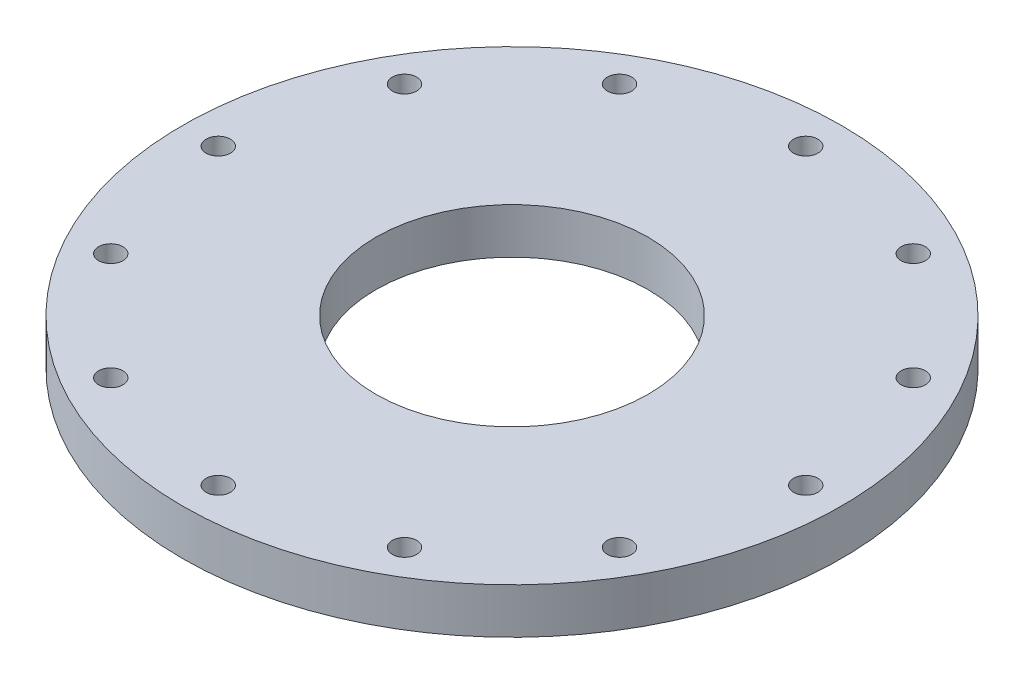
from build123d import *

# Parameters (mm, degrees)
SKETCH2_W            = 27
SKETCH2_H            = 6.35
M3_CLEARANCE_HOLE1_D = 3.4
CIRPATTERN1_COUNT    = 12


with BuildPart() as part:
    # Sketch2 → Revolve1 (revolve)
    with BuildSketch(Plane(origin=(0, 0, 0), x_dir=(0, 0, -1), z_dir=(1, 0, 0))):
        with Locations((-32.5, 3.175)):
            Rectangle(SKETCH2_W, SKETCH2_H)
    revolve(axis=Axis((0, 0, 0), (0, 1, 0)))

    # M3 Clearance Hole1 (through all)
    with Locations(Plane(origin=(0, 6.35, 0), x_dir=(1, 0, 0), z_dir=(0, 1, 0))):
        with Locations((0, 41)):
            m3_clearance_hole1 = Hole(M3_CLEARANCE_HOLE1_D / 2)

    # CirPattern1: M3 Clearance Hole1 ×12 about axis
    cirpattern1_axis = Axis((0, 0, 0), (0, 1, 0))
    for i in range(1, CIRPATTERN1_COUNT):
        add(m3_clearance_hole1.rotate(cirpattern1_axis, i * 360 / CIRPATTERN1_COUNT), mode=Mode.SUBTRACT)


solid = part.part
